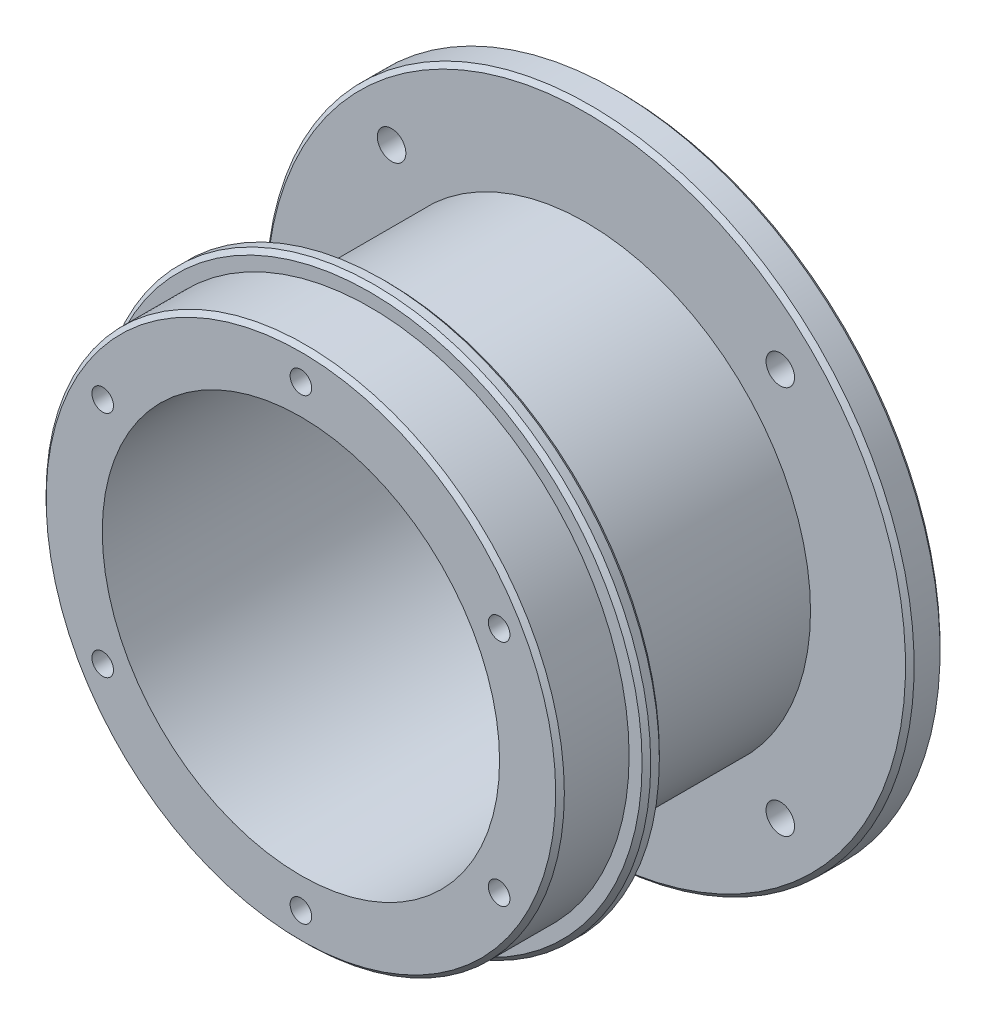
from build123d import *

# Parameters (mm, degrees)
SKETCH_1_R             = 32
EXTRUDE_1_DEPTH        = 2
SKETCH_2_R             = 30
EXTRUDE_2_DEPTH        = 8
SKETCH_3_R             = 23
CUT_EXTRUDE_1_DEPTH    = 11
SKETCH_4_R             = 26
SKETCH_4_R_2           = 23
EXTRUDE_3_DEPTH        = 23
SKETCH_5_R             = 37.5
SKETCH_5_R_2           = 1.75
SKETCH_5_R_3           = 26
SKETCH_5_R_4           = 23
EXTRUDE_4_DEPTH        = 4
HOLE_WIZARD_M4_3_D     = 3.3
HOLE_WIZARD_M4_3_DEPTH = 8.1
HOLE_WIZARD_M4_3_TIP   = 0.991420021
CHAMFER_1_SIZE         = 0.5
HOLE_WIZARD_M3_1_D     = 2.5
HOLE_WIZARD_M3_1_DEPTH = 6
HOLE_WIZARD_M3_1_TIP   = 0.751075774
CHAMFER_2_SIZE         = 0.5
CHAMFER_3_SIZE         = 0.5


with BuildPart() as part:
    # 草图1 → 凸台-拉伸1 (new body)
    with BuildSketch(Plane.XY):
        Circle(SKETCH_1_R)
    extrude(amount=EXTRUDE_1_DEPTH)

    # 草图2 → 凸台-拉伸2 (add)
    with BuildSketch(Plane.XY.offset(2)):
        Circle(SKETCH_2_R)
    extrude(amount=EXTRUDE_2_DEPTH)

    # 草图3 → 切除-拉伸1 (cut, through all)
    with BuildSketch(Plane(origin=(0, 0, 0), x_dir=(-1, 0, 0), z_dir=(0, 0, -1))):
        Circle(SKETCH_3_R)
    extrude(amount=-CUT_EXTRUDE_1_DEPTH, mode=Mode.SUBTRACT)

    # 草图4 → 凸台-拉伸3 (add)
    with BuildSketch(Plane(origin=(0, 0, 0), x_dir=(-1, 0, 0), z_dir=(0, 0, -1))):
        Circle(SKETCH_4_R)
        Circle(SKETCH_4_R_2, mode=Mode.SUBTRACT)
    extrude(amount=EXTRUDE_3_DEPTH)

    # 草图5 → 凸台-拉伸4 (add)
    with BuildSketch(Plane(origin=(0, 0, -23), x_dir=(-1, 0, 0), z_dir=(0, 0, -1))):
        Circle(SKETCH_5_R)
        with Locations((22.5, 22.5)):
            Circle(SKETCH_5_R_2, mode=Mode.SUBTRACT)
        with Locations((-22.5, 22.5)):
            Circle(SKETCH_5_R_2, mode=Mode.SUBTRACT)
        with Locations((-22.5, -22.5)):
            Circle(SKETCH_5_R_2, mode=Mode.SUBTRACT)
        with Locations((22.5, -22.5)):
            Circle(SKETCH_5_R_2, mode=Mode.SUBTRACT)
        Circle(SKETCH_5_R_3, mode=Mode.SUBTRACT)
        with Locations((22.5, 22.5)):
            Circle(SKETCH_5_R_2)
        with Locations((-22.5, 22.5)):
            Circle(SKETCH_5_R_2)
        with Locations((-22.5, -22.5)):
            Circle(SKETCH_5_R_2)
        with Locations((22.5, -22.5)):
            Circle(SKETCH_5_R_2)
        Circle(SKETCH_5_R_3)
        Circle(SKETCH_5_R_4, mode=Mode.SUBTRACT)
    extrude(amount=EXTRUDE_4_DEPTH)

    # M4 螺纹孔3
    with Locations(Plane(origin=(-22.5, -22.5, -27), x_dir=(-1, 0, 0), z_dir=(0, 0, -1))):
        with Locations((0, 0), (0, 45), (-45, 0), (-45, 45)):
            Hole(HOLE_WIZARD_M4_3_D / 2, depth=HOLE_WIZARD_M4_3_DEPTH)
            with Locations((0, 0, -(HOLE_WIZARD_M4_3_DEPTH + HOLE_WIZARD_M4_3_TIP / 2))):  # 118° drill point
                Cone(0, HOLE_WIZARD_M4_3_D / 2, HOLE_WIZARD_M4_3_TIP, mode=Mode.SUBTRACT)

    # 倒角1
    chamfer_1_edges = [part.edges().sort_by_distance(p)[0] for p in [
        (-32, 0, 0),
    ]]
    chamfer(chamfer_1_edges, length=CHAMFER_1_SIZE)

    # M3 螺纹孔1
    with Locations(Plane(origin=(0, -26.5, 10), x_dir=(1, 0, 0), z_dir=(0, 0, 1))):
        with Locations((0, 0), (22.9496732, 13.25), (22.9496732, 39.75), (0, 53), (-22.9496732, 39.75), (-22.9496732, 13.25)):
            Hole(HOLE_WIZARD_M3_1_D / 2, depth=HOLE_WIZARD_M3_1_DEPTH)
            with Locations((0, 0, -(HOLE_WIZARD_M3_1_DEPTH + HOLE_WIZARD_M3_1_TIP / 2))):  # 118° drill point
                Cone(0, HOLE_WIZARD_M3_1_D / 2, HOLE_WIZARD_M3_1_TIP, mode=Mode.SUBTRACT)

    # 倒角2
    chamfer_2_edges = [part.edges().sort_by_distance(p)[0] for p in [
        (37.5, 0, -23),
        (37.5, 0, -27),
    ]]
    chamfer(chamfer_2_edges, length=CHAMFER_2_SIZE)

    # 倒角3
    chamfer_3_edges = [part.edges().sort_by_distance(p)[0] for p in [
        (-32, 0, 2),
        (-30, 0, 10),
    ]]
    chamfer(chamfer_3_edges, length=CHAMFER_3_SIZE)


solid = part.part
